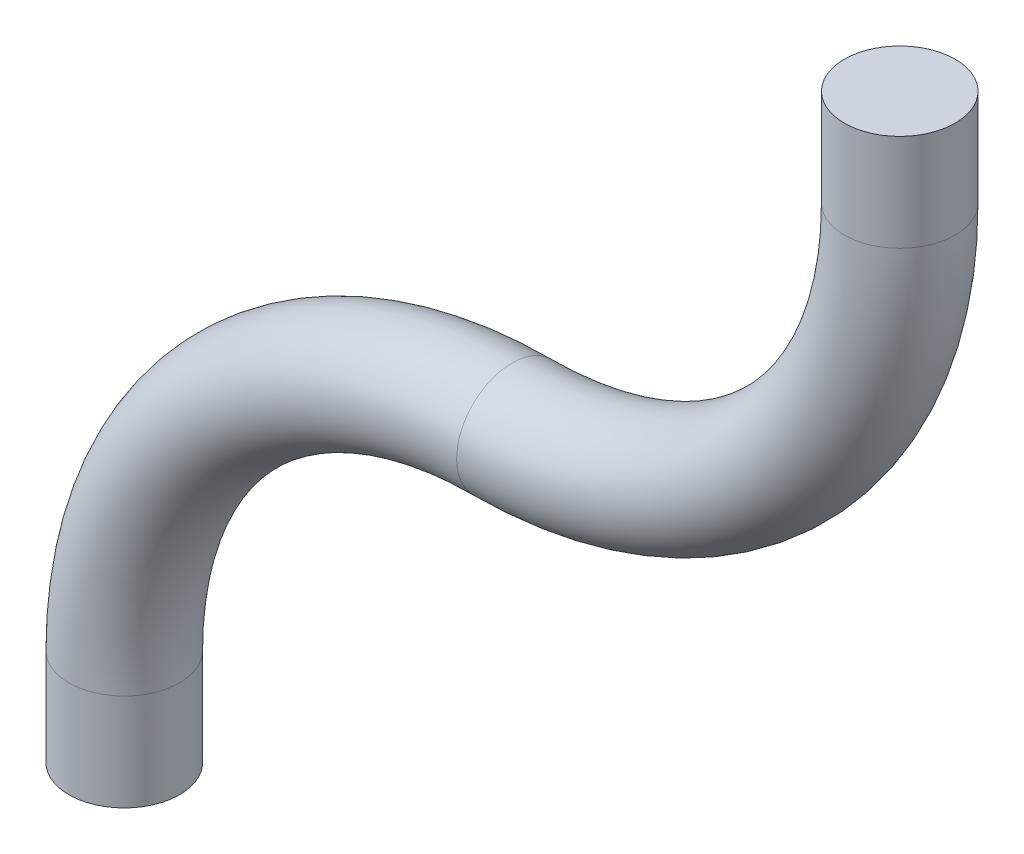
from build123d import *

# Parameters (mm, degrees)
BALAYAGE1_PROFILE_R = 3.2


with BuildPart() as part:
    # Balayage1: sweep along a path in Esquisse1
    with BuildLine(Plane.XY) as balayage1_path:
        Line((0, -5.6), (0, 0))
        ThreePointArc((0, 0), (6.560808101, 15.839191899), (22.4, 22.4))
        ThreePointArc((22.4, 22.4), (38.239191899, 28.960808101), (44.8, 44.8))
        Line((44.8, 44.8), (44.8, 50.4))
    # Balayage1 profile (on start of the path) → Balayage1 (sweep)
    with BuildSketch(Plane(origin=(0, -5.6, 0), x_dir=(1, 0, 0), z_dir=(0, 1, 0))):
        Circle(BALAYAGE1_PROFILE_R)
    sweep(path=balayage1_path.line)


solid = part.part
